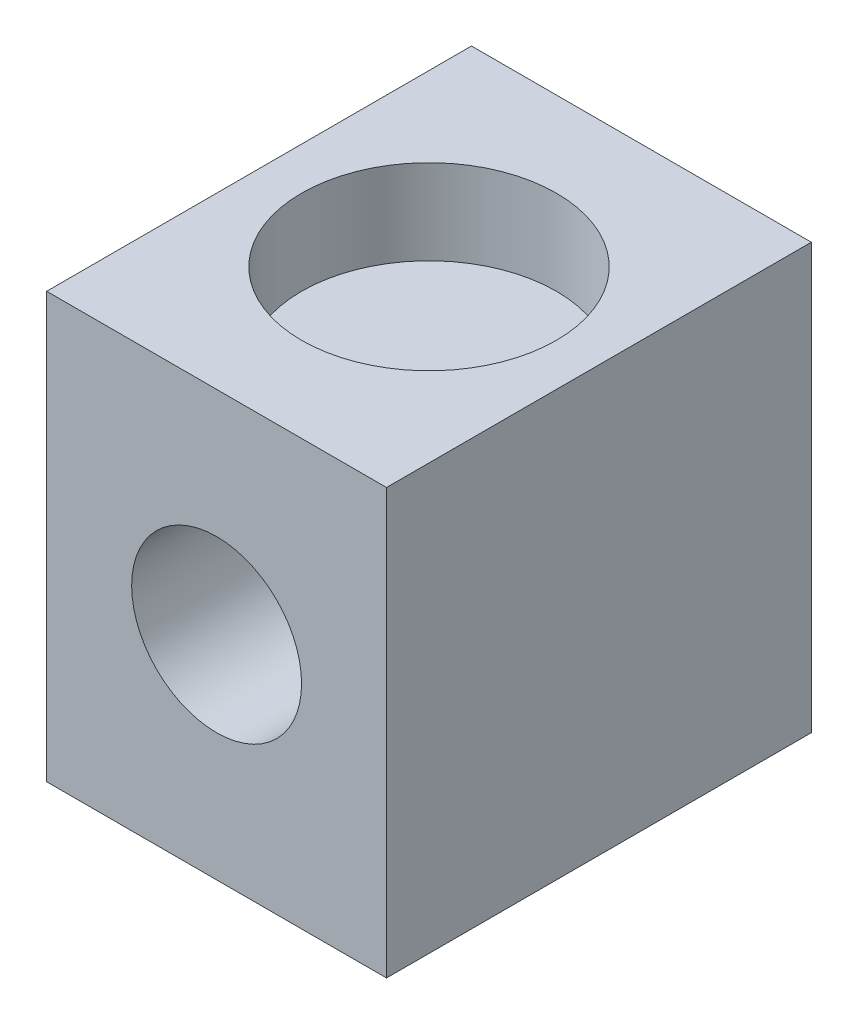
from build123d import *

# Parameters (mm, degrees)
CROQUIS1_W              = 4
CROQUIS1_H              = 5
CROQUIS1_R              = 1
SALIENTE_EXTRUIR1_DEPTH = 5
CROQUIS3_R              = 1.5
CORTAR_EXTRUIR1_DEPTH   = 1


with BuildPart() as part:
    # Croquis1 → Saliente-Extruir1 (new body)
    with BuildSketch(Plane.XY):
        Rectangle(CROQUIS1_W, CROQUIS1_H)
        Circle(CROQUIS1_R, mode=Mode.SUBTRACT)
    extrude(amount=SALIENTE_EXTRUIR1_DEPTH)

    # Croquis3 → Cortar-Extruir1 (cut)
    with BuildSketch(Plane(origin=(0, 2.5, 0), x_dir=(1, 0, 0), z_dir=(0, 1, 0))):
        with Locations((0, -2.5)):
            Circle(CROQUIS3_R)
    cortar_extruir1 = extrude(amount=-CORTAR_EXTRUIR1_DEPTH, mode=Mode.SUBTRACT)

    # Simetría1: Cortar-Extruir1 across plane
    add(cortar_extruir1.mirror(Plane(origin=(0, 0, 0), x_dir=(0, 0, 1), z_dir=(0, -1, 0))), mode=Mode.SUBTRACT)


solid = part.part
